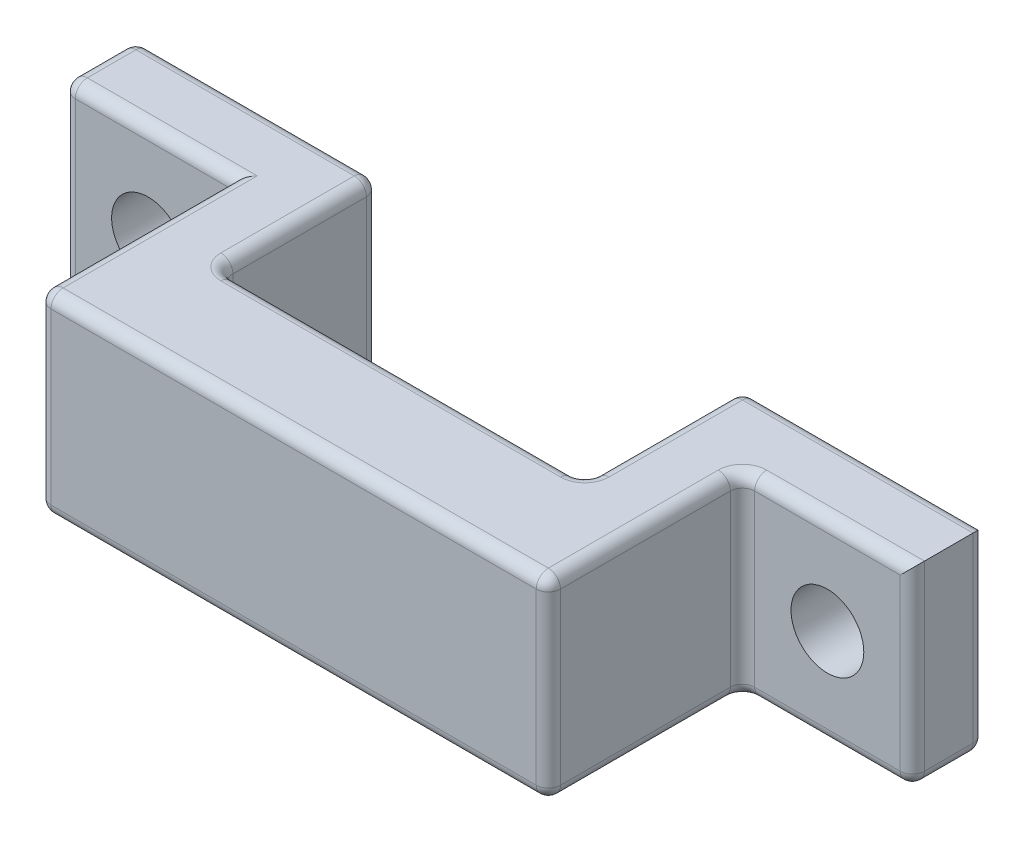
from build123d import *

# Parameters (mm, degrees)
SKETCH1_W           = 35
SKETCH1_H           = 8
BOSS_EXTRUDE1_DEPTH = 11
CUT_EXTRUDE1_REACH  = 10
SKETCH2_W           = 15
SKETCH2_H           = 6.5
CUT_EXTRUDE2_REACH  = 10
SKETCH5_W           = 7
SKETCH5_H           = 8
CUT_EXTRUDE4_REACH  = 5
SKETCH7_R           = 1.5
FILLET1_R           = 0.5


with BuildPart() as part:
    # Sketch1 → Boss-Extrude1 (new body)
    with BuildSketch(Plane.XY):
        with Locations((-12, -20.425)):
            Rectangle(SKETCH1_W, SKETCH1_H)
    extrude(amount=BOSS_EXTRUDE1_DEPTH)

    # Sketch2 → Cut-Extrude1 (cut, up to next)
    with BuildSketch(Plane(origin=(0, -24.425, 0), x_dir=(-1, 0, 0), z_dir=(0, -1, 0)), mode=Mode.PRIVATE) as cut_extrude1_sk1:
        with Locations((12, -3.25)):
            Rectangle(SKETCH2_W, SKETCH2_H)
    cut_extrude1_tool1 = extrude(cut_extrude1_sk1.sketch, amount=-CUT_EXTRUDE1_REACH, mode=Mode.PRIVATE) & part.part
    add(cut_extrude1_tool1.solids().sort_by_distance((-12, -24.425, 3.25))[0], mode=Mode.SUBTRACT)

    # Sketch5 → Cut-Extrude2 (cut, up to next)
    with BuildSketch(Plane(origin=(0, -24.425, 0), x_dir=(-1, 0, 0), z_dir=(0, -1, 0)), mode=Mode.PRIVATE) as cut_extrude2_sk1:
        with Locations((-2, -7)):
            Rectangle(SKETCH5_W, SKETCH5_H)
    cut_extrude2_tool1 = extrude(cut_extrude2_sk1.sketch, amount=-CUT_EXTRUDE2_REACH, mode=Mode.PRIVATE) & part.part
    add(cut_extrude2_tool1.solids().sort_by_distance((2, -24.425, 7))[0], mode=Mode.SUBTRACT)
    # Sketch5 → Cut-Extrude2 (cut, up to next)
    with BuildSketch(Plane(origin=(0, -24.425, 0), x_dir=(-1, 0, 0), z_dir=(0, -1, 0)), mode=Mode.PRIVATE) as cut_extrude2_sk2:
        with Locations((26, -7)):
            Rectangle(SKETCH5_W, SKETCH5_H)
    cut_extrude2_tool2 = extrude(cut_extrude2_sk2.sketch, amount=-CUT_EXTRUDE2_REACH, mode=Mode.PRIVATE) & part.part
    add(cut_extrude2_tool2.solids().sort_by_distance((-26, -24.425, 7))[0], mode=Mode.SUBTRACT)

    # Sketch7 → Cut-Extrude4 (cut, up to next)
    with BuildSketch(Plane.XY.offset(3), mode=Mode.PRIVATE) as cut_extrude4_sk1:
        with Locations((2, -20.425)):
            Circle(SKETCH7_R)
    cut_extrude4_tool1 = extrude(cut_extrude4_sk1.sketch, amount=-CUT_EXTRUDE4_REACH, mode=Mode.PRIVATE) & part.part
    add(cut_extrude4_tool1.solids().sort_by_distance((2, -20.425, 3))[0], mode=Mode.SUBTRACT)
    # Sketch7 → Cut-Extrude4 (cut, up to next)
    with BuildSketch(Plane.XY.offset(3), mode=Mode.PRIVATE) as cut_extrude4_sk2:
        with Locations((-26, -20.425)):
            Circle(SKETCH7_R)
    cut_extrude4_tool2 = extrude(cut_extrude4_sk2.sketch, amount=-CUT_EXTRUDE4_REACH, mode=Mode.PRIVATE) & part.part
    add(cut_extrude4_tool2.solids().sort_by_distance((-26, -20.425, 3))[0], mode=Mode.SUBTRACT)

    # Fillet1
    fillet1_edges = [part.edges().sort_by_distance(p)[0] for p in [
        (-24.5, -16.425, 0),
        (0.5, -24.425, 0),
        (-19.5, -20.425, 0),
        (-19.5, -20.425, 6.5),
        (-4.5, -20.425, 6.5),
        (-4.5, -20.425, 0),
        (-19.5, -24.425, 3.25),
        (-4.5, -24.425, 3.25),
        (-12, -24.425, 6.5),
        (-19.5, -16.425, 3.25),
        (-12, -16.425, 6.5),
        (-4.5, -16.425, 3.25),
        (-12, -24.425, 11),
        (-12, -16.425, 11),
        (-29.5, -16.425, 1.5),
        (5.5, -24.425, 1.5),
        (-29.5, -24.425, 1.5),
        (5.5, -20.425, 3),
        (-1.5, -20.425, 3),
        (-1.5, -20.425, 11),
        (-1.5, -24.425, 7),
        (2, -24.425, 3),
        (2, -16.425, 3),
        (-1.5, -16.425, 7),
        (-29.5, -20.425, 3),
        (-22.5, -20.425, 11),
        (-26, -24.425, 3),
        (-22.5, -24.425, 7),
        (-22.5, -16.425, 7),
        (-26, -16.425, 3),
        (0.5, -16.425, 0),
        (5.5, -20.425, 0),
        (-24.5, -24.425, 0),
        (-29.5, -20.425, 0),
    ]]
    fillet(fillet1_edges, radius=FILLET1_R)


solid = part.part
